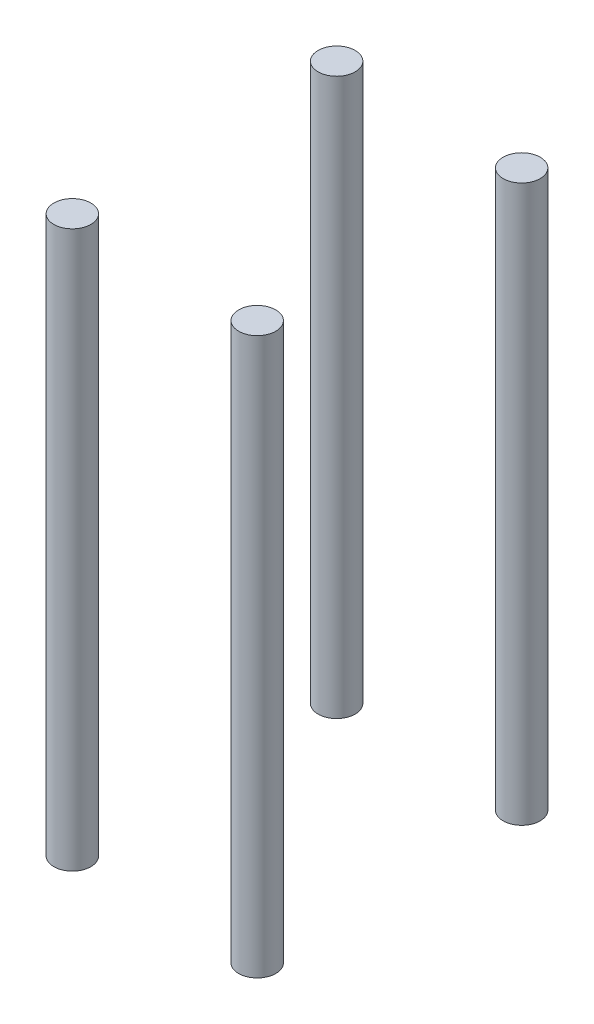
from build123d import *

# Parameters (mm, degrees)
SKETCH2_R             = 4
BOSS_EXTRUDE1_DEPTH   = 120
BOSS_EXTRUDE1_2_DEPTH = 120
BOSS_EXTRUDE1_3_DEPTH = 120
BOSS_EXTRUDE1_4_DEPTH = 120


with BuildPart() as part:
    # Sketch2 → Boss-Extrude1 (new body)
    with BuildSketch(Plane(origin=(0, 0, 0), x_dir=(1, 0, 0), z_dir=(0, 1, 0))):
        with Locations((19.325260187, 28.518864445)):
            Circle(SKETCH2_R)
    extrude(amount=BOSS_EXTRUDE1_DEPTH)


with BuildPart() as body_2:
    # Sketch2 → Boss-Extrude1 2 (new body)
    with BuildSketch(Plane(origin=(0, 0, 0), x_dir=(1, 0, 0), z_dir=(0, 1, 0))):
        with Locations((-20.575260187, 28.505316266)):
            Circle(SKETCH2_R)
    extrude(amount=BOSS_EXTRUDE1_2_DEPTH)


with BuildPart() as body_3:
    # Sketch2 → Boss-Extrude1 3 (new body)
    with BuildSketch(Plane(origin=(0, 0, 0), x_dir=(1, 0, 0), z_dir=(0, 1, 0))):
        with Locations((19.325260187, -28.518864445)):
            Circle(SKETCH2_R)
    extrude(amount=BOSS_EXTRUDE1_3_DEPTH)


with BuildPart() as body_4:
    # Sketch2 → Boss-Extrude1 4 (new body)
    with BuildSketch(Plane(origin=(0, 0, 0), x_dir=(1, 0, 0), z_dir=(0, 1, 0))):
        with Locations((-20.575260187, -28.505316266)):
            Circle(SKETCH2_R)
    extrude(amount=BOSS_EXTRUDE1_4_DEPTH)


solid = Compound([part.part, body_2.part, body_3.part, body_4.part])
